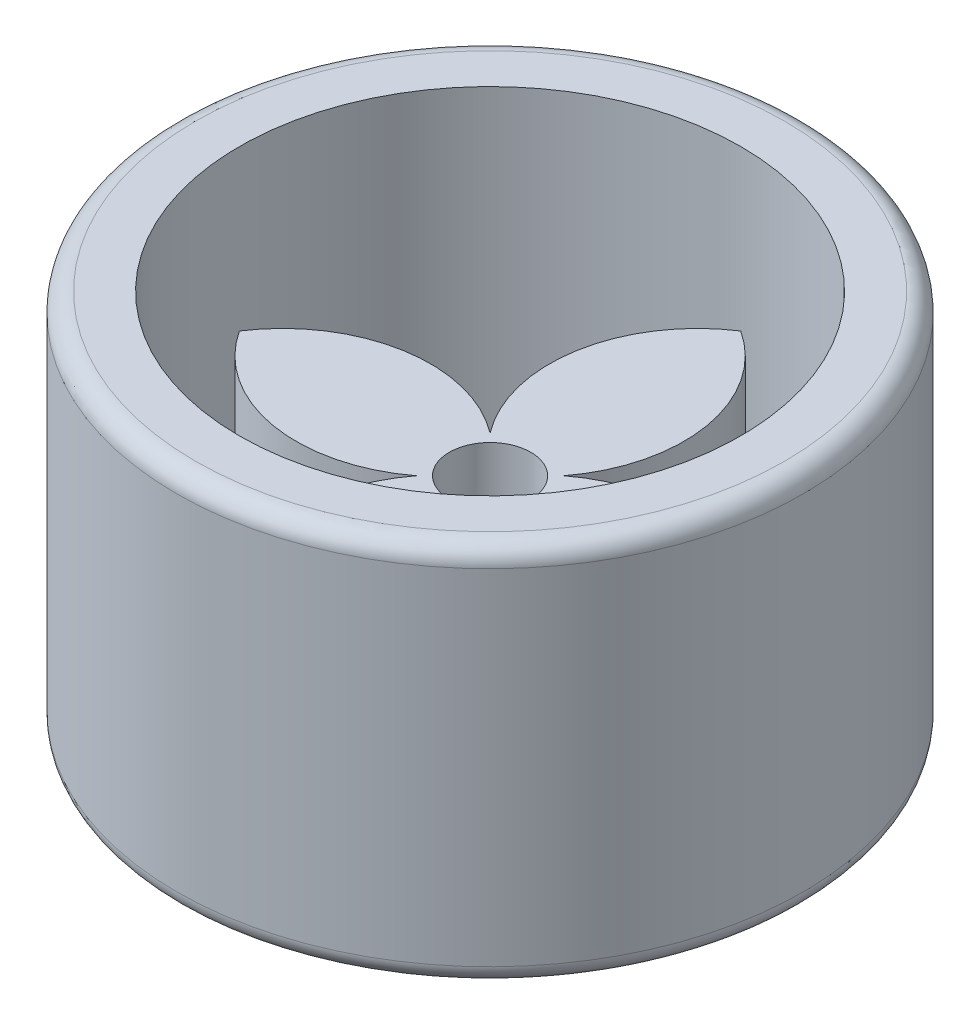
from build123d import *

# Parameters (mm, degrees)
SKETCH1_R           = 50
SKETCH1_R_2         = 40
BOSS_EXTRUDE1_DEPTH = 61
SKETCH1_3_R         = 2.635
BOSS_EXTRUDE2_DEPTH = 35.5
FILLET1_R           = 3
SKETCH2_R           = 6.5
CUT_EXTRUDE1_DEPTH  = 14.6
SKETCH3_R           = 4.95
CUT_EXTRUDE2_DEPTH  = 1
CUT_EXTRUDE3_START  = -1
SKETCH3_3_R         = 2.635
CUT_EXTRUDE3_DEPTH  = 7.95


with BuildPart() as part:
    # Sketch1 → Boss-Extrude1 (new body)
    with BuildSketch(Plane(origin=(0, 0, 0), x_dir=(1, 0, 0), z_dir=(0, 1, 0))):
        Circle(SKETCH1_R)
        Circle(SKETCH1_R_2, mode=Mode.SUBTRACT)
    extrude(amount=BOSS_EXTRUDE1_DEPTH)

    # Fillet1
    fillet1_edges = [part.edges().sort_by_distance(p)[0] for p in [
        (-50, 61, 0),
        (-50, 0, 0),
    ]]
    fillet(fillet1_edges, radius=FILLET1_R)


with BuildPart() as body_2:
    # Sketch1_3 → Boss-Extrude2 (new body)
    with BuildSketch(Plane(origin=(0, 0, 0), x_dir=(1, 0, 0), z_dir=(0, 1, 0))):
        with BuildLine():
            ThreePointArc((5.877030144, 5.877030144), (24.220657484, 10.382837425), (40, 0))
            ThreePointArc((40, 0), (24.220657484, -10.382837425), (5.877030144, -5.877030144))
            ThreePointArc((5.877030144, -5.877030144), (10.382837425, -24.220657484), (0, -40))
            ThreePointArc((0, -40), (-10.382837425, -24.220657484), (-5.877030144, -5.877030144))
            ThreePointArc((-5.877030144, -5.877030144), (-24.220657484, -10.382837425), (-40, 0))
            ThreePointArc((-40, 0), (-24.220657484, 10.382837425), (-5.877030144, 5.877030144))
            ThreePointArc((-5.877030144, 5.877030144), (-10.382837425, 24.220657484), (0, 40))
            ThreePointArc((0, 40), (10.382837425, 24.220657484), (5.877030144, 5.877030144))
        make_face()
        Circle(SKETCH1_3_R, mode=Mode.SUBTRACT)
    extrude(amount=BOSS_EXTRUDE2_DEPTH)

    # Sketch2 → Cut-Extrude1 (cut)
    with BuildSketch(Plane(origin=(0, 35.5, 0), x_dir=(1, 0, 0), z_dir=(0, 1, 0))):
        Circle(SKETCH2_R)
    extrude(amount=-CUT_EXTRUDE1_DEPTH, mode=Mode.SUBTRACT)

    # Sketch3 → Cut-Extrude2 (cut)
    with BuildSketch(Plane(origin=(0, 20.9, 0), x_dir=(1, 0, 0), z_dir=(0, 1, 0))):
        Circle(SKETCH3_R)
    extrude(amount=-CUT_EXTRUDE2_DEPTH, mode=Mode.SUBTRACT)

    # Sketch3_3 → Cut-Extrude3 (cut)
    with BuildSketch(Plane(origin=(0, 20.9, 0), x_dir=(1, 0, 0), z_dir=(0, 1, 0)).offset(CUT_EXTRUDE3_START)):
        Polygon((2.309401077, -4), (4.618802154, 0), (2.309401077, 4), (-2.309401077, 4), (-4.618802154, 0), (-2.309401077, -4), align=None)
        Circle(SKETCH3_3_R, mode=Mode.SUBTRACT)
    extrude(amount=-CUT_EXTRUDE3_DEPTH, mode=Mode.SUBTRACT)


solid = Compound([part.part, body_2.part])
